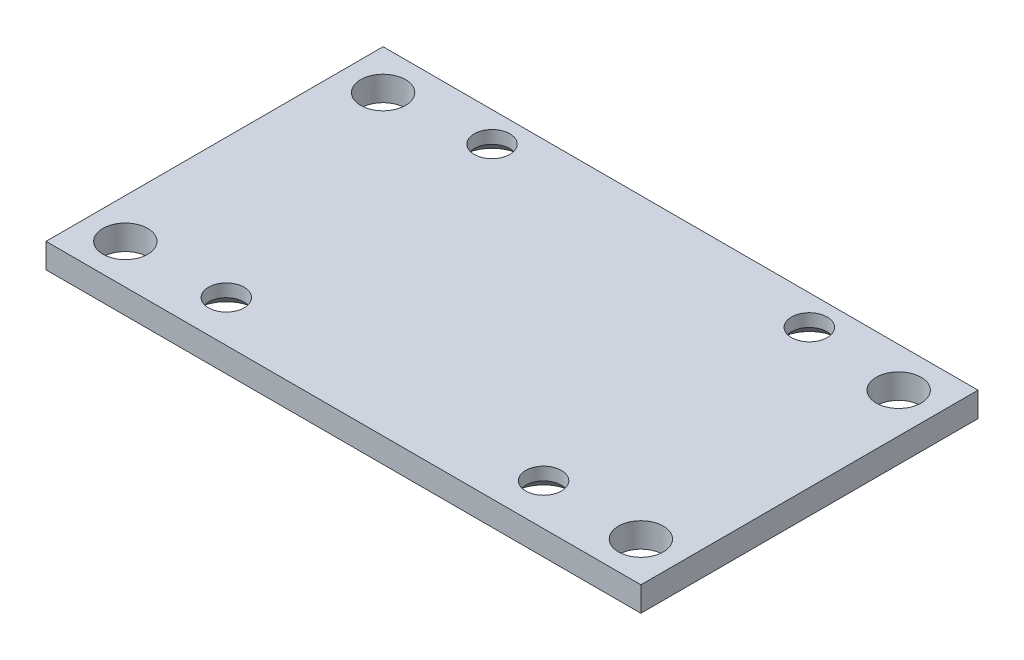
from build123d import *

# Parameters (mm, degrees)
SKETCH1_W                       = 30
SKETCH1_H                       = 17
BOSS_EXTRUDE1_DEPTH             = 1.2446
M1_6_CLEARANCE_HOLE1_AT_2_COUNT = 2
M1_6_CLEARANCE_HOLE1_AT_2_PITCH = 16
M1_6_CLEARANCE_HOLE1_AT_3_COUNT = 2
M1_6_CLEARANCE_HOLE1_AT_3_PITCH = 13.4
M1_6_CLEARANCE_HOLE1_AT_4_COUNT = 2
M1_6_CLEARANCE_HOLE1_AT_4_PITCH = 20.870074269
F_2_CLEARANCE_HOLE1_D           = 2.2606
F_2_CLEARANCE_HOLE1_DEPTH       = 2.032
F_2_CLEARANCE_HOLE1_TIP         = 0.679152758


with BuildPart() as part:
    # Sketch1 → Boss-Extrude1 (new body)
    with BuildSketch(Plane(origin=(0, 0, 0), x_dir=(1, 0, 0), z_dir=(0, 1, 0))):
        Rectangle(SKETCH1_W, SKETCH1_H)
    extrude(amount=BOSS_EXTRUDE1_DEPTH)

    # Sketch4 → M1.6 Clearance Hole1 (revolve, cut)
    with BuildSketch(Plane(origin=(-8, 0, 6.407104521), x_dir=(0, 0, -1), z_dir=(1, 0, 0))):
        Polygon((0, 0), (0, 1.2446), (0.9, 1.2446), (0.9, 0.6), (1.5, 0), align=None)
    m1_6_clearance_hole1 = revolve(axis=Axis((-8, -6.35, 6.407104521), (0, 1, 0)), mode=Mode.SUBTRACT)

    # M1.6 Clearance Hole1 at 2: M1.6 Clearance Hole1 ×2
    with Locations(*[(i * M1_6_CLEARANCE_HOLE1_AT_2_PITCH, 0, 0) for i in range(1, M1_6_CLEARANCE_HOLE1_AT_2_COUNT)]):
        add(m1_6_clearance_hole1, mode=Mode.SUBTRACT)

    # M1.6 Clearance Hole1 at 3: M1.6 Clearance Hole1 ×2
    with Locations(*[(0, 0, -i * M1_6_CLEARANCE_HOLE1_AT_3_PITCH) for i in range(1, M1_6_CLEARANCE_HOLE1_AT_3_COUNT)]):
        add(m1_6_clearance_hole1, mode=Mode.SUBTRACT)

    # M1.6 Clearance Hole1 at 4: M1.6 Clearance Hole1 ×2
    with Locations(*[Vector(0.766647967, 0, -0.642067672) * (i * M1_6_CLEARANCE_HOLE1_AT_4_PITCH) for i in range(1, M1_6_CLEARANCE_HOLE1_AT_4_COUNT)]):
        add(m1_6_clearance_hole1, mode=Mode.SUBTRACT)

    # #2 Clearance Hole1
    with Locations(Plane(origin=(0, 1.2446, 0), x_dir=(-1, 0, 0), z_dir=(0, 1, 0))):
        with Locations((13, -6.5), (13, 6.5), (-13, -6.5), (-13, 6.5)):
            Hole(F_2_CLEARANCE_HOLE1_D / 2, depth=F_2_CLEARANCE_HOLE1_DEPTH)
            with Locations((0, 0, -(F_2_CLEARANCE_HOLE1_DEPTH + F_2_CLEARANCE_HOLE1_TIP / 2))):  # 118° drill point
                Cone(0, F_2_CLEARANCE_HOLE1_D / 2, F_2_CLEARANCE_HOLE1_TIP, mode=Mode.SUBTRACT)


solid = part.part
